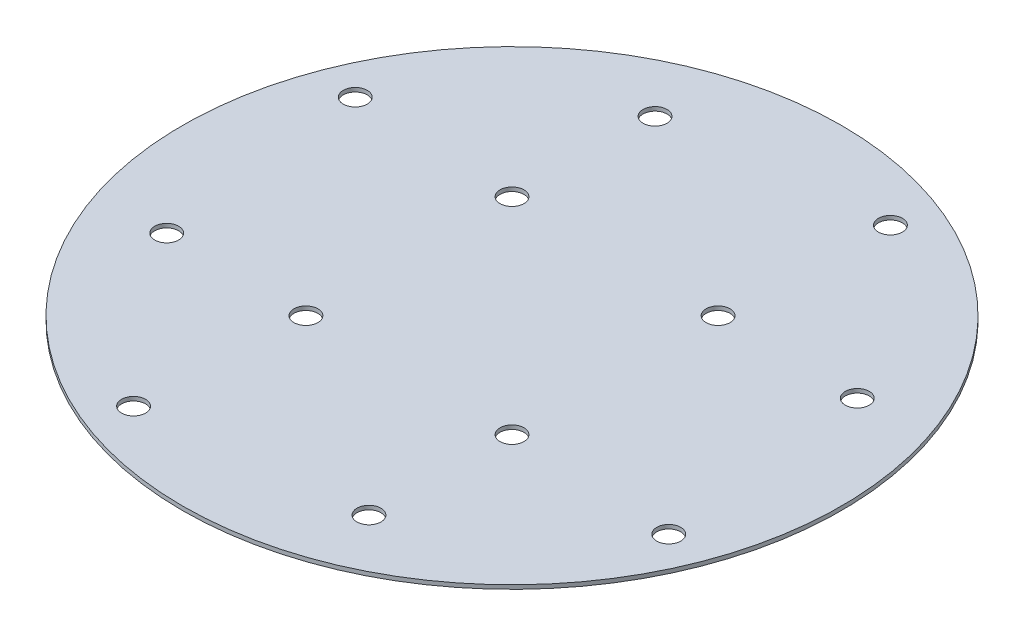
from build123d import *

# Parameters (mm, degrees)
SKETCH2_W                    = 82.55
SKETCH2_H                    = 1
F_10_0_1935_DIAMETER_HOLE1_D = 5.999999938
CIRPATTERN3_COUNT            = 4


with BuildPart() as part:
    # Sketch2 → Revolve1 (revolve)
    with BuildSketch(Plane(origin=(0, 0, 0), x_dir=(0, 0, -1), z_dir=(1, 0, 0))):
        with Locations((-41.275, 0.5)):
            Rectangle(SKETCH2_W, SKETCH2_H)
    revolve(axis=Axis((0, -0.05, 0), (0, 1, 0)))

    # #10 (0.1935) Diameter Hole1 (through all)
    with Locations(Plane(origin=(0, 1, 0), x_dir=(1, 0, 0), z_dir=(0, 1, 0))):
        with Locations((-25.333643223, 61.160825052), (264.743675233, 73.787758551), (-67.027460084, 27.763683018), (-25.809397513, 25.809397513)):
            f_10_0_1935_diameter_hole1 = Hole(F_10_0_1935_DIAMETER_HOLE1_D / 2)

    # CirPattern3: #10 (0.1935) Diameter Hole1 ×4 about axis
    cirpattern3_axis = Axis((0, 0, 0), (0, 1, 0))
    for i in range(1, CIRPATTERN3_COUNT):
        add(f_10_0_1935_diameter_hole1.rotate(cirpattern3_axis, i * 360 / CIRPATTERN3_COUNT), mode=Mode.SUBTRACT)


solid = part.part
